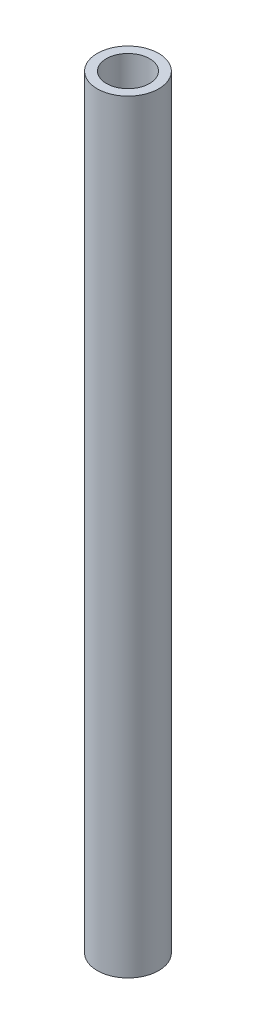
from build123d import *

# Parameters (mm, degrees)
SKETCH_1_R      = 18.5
SKETCH_1_R_2    = 13
EXTRUDE_1_DEPTH = 460


with BuildPart() as part:
    # 草图1 → 凸台-拉伸1 (new body)
    with BuildSketch(Plane(origin=(0, 0, 0), x_dir=(1, 0, 0), z_dir=(0, 1, 0))):
        Circle(SKETCH_1_R)
        Circle(SKETCH_1_R_2, mode=Mode.SUBTRACT)
    extrude(amount=EXTRUDE_1_DEPTH)


solid = part.part
